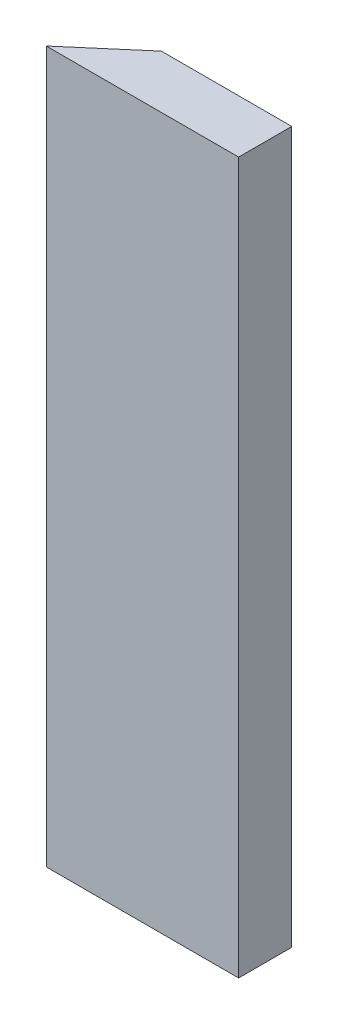
from build123d import *

# Parameters (mm, degrees)
SALIENTE_EXTRUIR1_DEPTH    = 170
CROQUIS2_W                 = 8
CROQUIS2_H                 = 27
CORTAR_EXTRUIR1_DEPTH      = 1
CORTAR_EXTRUIR1_DEPTH_BACK = 16
CROQUIS3_W                 = 38.06511858
CROQUIS3_H                 = 175.826127046
CORTAR_EXTRUIR2_DEPTH      = 1
CORTAR_EXTRUIR2_DEPTH_BACK = 16
CROQUIS4_W                 = 35.532251822
CROQUIS4_H                 = 7.536766594
CORTAR_EXTRUIR3_DEPTH      = 1
CORTAR_EXTRUIR3_DEPTH_BACK = 171


with BuildPart() as part:
    # Croquis1 → Saliente-Extruir1 (new body)
    with BuildSketch(Plane(origin=(0, 0, 0), x_dir=(1, 0, 0), z_dir=(0, 1, 0))):
        Polygon((0, 0), (17.50080029, 15), (60, 15), (60, 0), align=None)
    extrude(amount=SALIENTE_EXTRUIR1_DEPTH)

    # Croquis2 → Cortar-Extruir1 (cut, two sides)
    with BuildSketch(Plane(origin=(0, 0, -15), x_dir=(-1, 0, 0), z_dir=(0, 0, -1))) as cortar_extruir1_sk:
        with Locations((-56, 13.5)):
            Rectangle(CROQUIS2_W, CROQUIS2_H)
        with Locations((-56, 156.5)):
            Rectangle(CROQUIS2_W, CROQUIS2_H)
    extrude(amount=CORTAR_EXTRUIR1_DEPTH, mode=Mode.SUBTRACT)
    extrude(cortar_extruir1_sk.sketch, amount=-CORTAR_EXTRUIR1_DEPTH_BACK, mode=Mode.SUBTRACT)

    # Croquis3 → Cortar-Extruir2 (cut, two sides)
    with BuildSketch(Plane(origin=(0, 0, -15), x_dir=(-1, 0, 0), z_dir=(0, 0, -1))) as cortar_extruir2_sk:
        with Locations((-65.03255929, 82.086936477)):
            Rectangle(CROQUIS3_W, CROQUIS3_H)
    extrude(amount=CORTAR_EXTRUIR2_DEPTH, mode=Mode.SUBTRACT)
    extrude(cortar_extruir2_sk.sketch, amount=-CORTAR_EXTRUIR2_DEPTH_BACK, mode=Mode.SUBTRACT)

    # Croquis4 → Cortar-Extruir3 (cut, two sides)
    with BuildSketch(Plane.XZ) as cortar_extruir3_sk:
        with Locations((28.233874089, -16.468383297)):
            Rectangle(CROQUIS4_W, CROQUIS4_H)
    extrude(amount=CORTAR_EXTRUIR3_DEPTH, mode=Mode.SUBTRACT)
    extrude(cortar_extruir3_sk.sketch, amount=-CORTAR_EXTRUIR3_DEPTH_BACK, mode=Mode.SUBTRACT)


solid = part.part
